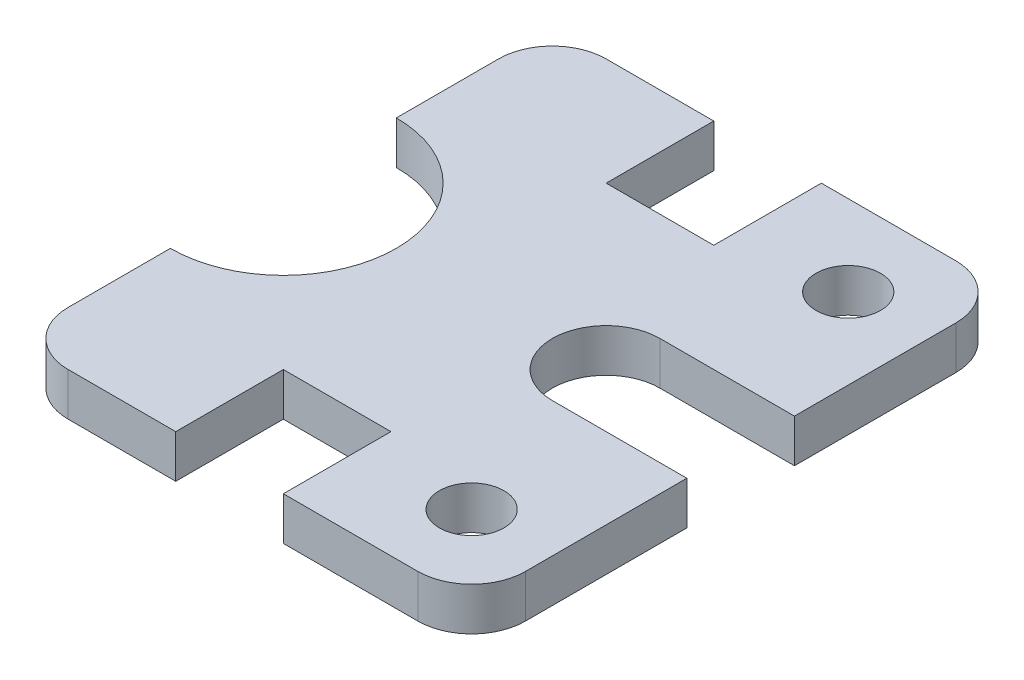
from build123d import *

# Parameters (mm, degrees)
SKETCH1_R           = 6
BOSS_EXTRUDE1_DEPTH = 8


with BuildPart() as part:
    # Sketch1 → Boss-Extrude1 (new body)
    with BuildSketch(Plane(origin=(0, 0, 0), x_dir=(1, 0, 0), z_dir=(0, 1, 0))):
        with BuildLine():
            Line((-25.10169054, -0.115674765), (-0.10169054, -0.115674765))
            Line((-0.10169054, -0.115674765), (-0.10169054, 29.884325235))
            ThreePointArc((-0.10169054, 29.884325235), (-3.030622728, 36.955393047), (-10.10169054, 39.884325235))
            Line((-10.10169054, 39.884325235), (-35.10169054, 39.884325235))
            Line((-35.10169054, 39.884325235), (-35.10169054, 19.884325235))
            Line((-35.10169054, 19.884325235), (-55.10169054, 19.884325235))
            Line((-55.10169054, 19.884325235), (-55.10169054, 39.884325235))
            Line((-55.10169054, 39.884325235), (-75.10169054, 39.884325235))
            ThreePointArc((-75.10169054, 39.884325235), (-82.172758352, 36.955393047), (-85.10169054, 29.884325235))
            Line((-85.10169054, 29.884325235), (-85.10169054, 10.884325235))
            ThreePointArc((-85.10169054, 10.884325235), (-64.10169054, -10.115674765), (-85.10169054, -31.115674765))
            Line((-85.10169054, -31.115674765), (-85.10169054, -50.115674765))
            ThreePointArc((-85.10169054, -50.115674765), (-82.172758352, -57.186742577), (-75.10169054, -60.115674765))
            Line((-75.10169054, -60.115674765), (-55.10169054, -60.115674765))
            Line((-55.10169054, -60.115674765), (-55.10169054, -40.115674765))
            Line((-55.10169054, -40.115674765), (-35.10169054, -40.115674765))
            Line((-35.10169054, -40.115674765), (-35.10169054, -60.115674765))
            Line((-35.10169054, -60.115674765), (-10.10169054, -60.115674765))
            ThreePointArc((-10.10169054, -60.115674765), (-3.030622728, -57.186742577), (-0.10169054, -50.115674765))
            Line((-0.10169054, -50.115674765), (-0.10169054, -20.115674765))
            Line((-0.10169054, -20.115674765), (-25.10169054, -20.115674765))
            ThreePointArc((-25.10169054, -20.115674765), (-35.10169054, -10.115674765), (-25.10169054, -0.115674765))
        make_face()
        with Locations((-15.10169054, 24.884325235)):
            Circle(SKETCH1_R, mode=Mode.SUBTRACT)
        with Locations((-15.10169054, -45.115674765)):
            Circle(SKETCH1_R, mode=Mode.SUBTRACT)
    extrude(amount=BOSS_EXTRUDE1_DEPTH)


solid = part.part
